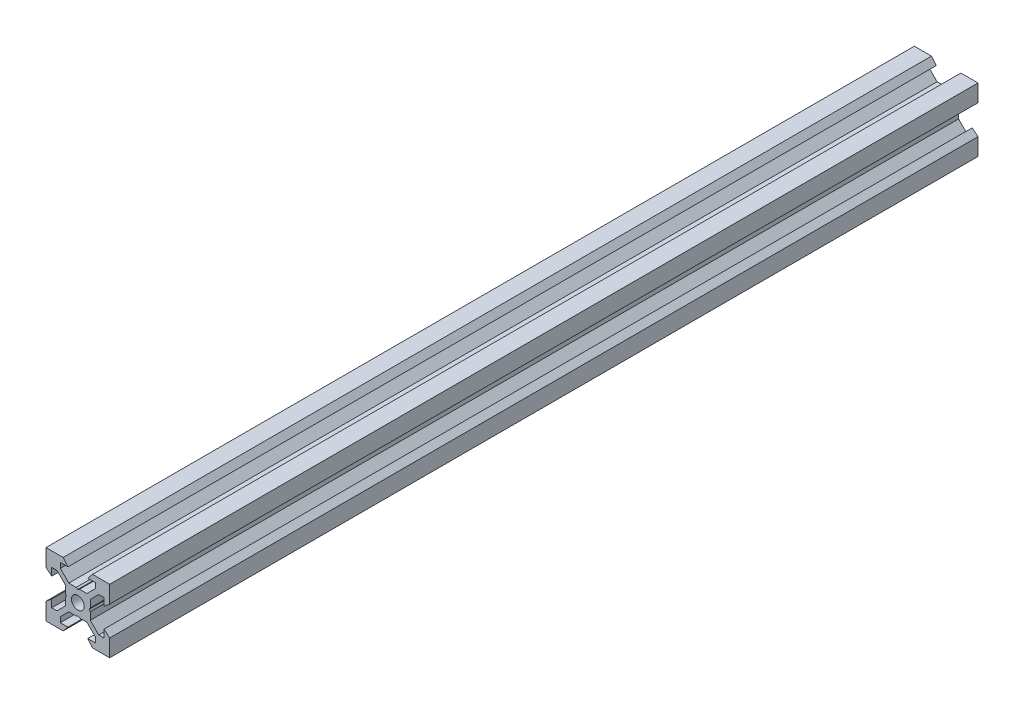
from build123d import *

# Parameters (mm, degrees)
SKETCH1_R           = 2
BOSS_EXTRUDE1_DEPTH = 136.375


with BuildPart() as part:
    # Sketch1 → Boss-Extrude1 (new body, symmetric)
    with BuildSketch(Plane.XY):
        Polygon((10, 10), (10, 4.610379336), (8.2, 3.1), (8.2, 5.5), (6.560660172, 5.5), (3.9, 2.839339828), (3.9, 0.519615242), (3.6, 0), (3.9, -0.519615242), (3.9, -2.839339828), (6.560660172, -5.5), (8.2, -5.5), (8.2, -3.1), (10, -4.610379336), (10, -10), (4.610379336, -10), (3.1, -8.2), (5.5, -8.2), (5.5, -6.560660172), (2.839339828, -3.9), (0.519615242, -3.9), (0, -3.6), (-0.519615242, -3.9), (-2.839339828, -3.9), (-5.5, -6.560660172), (-5.5, -8.2), (-3.1, -8.2), (-4.610379336, -10), (-10, -10), (-10, -4.610379336), (-8.2, -3.1), (-8.2, -5.5), (-6.560660172, -5.5), (-3.9, -2.839339828), (-3.9, -0.519615242), (-3.6, 0), (-3.9, 0.519615242), (-3.9, 2.839339828), (-6.560660172, 5.5), (-8.2, 5.5), (-8.2, 3.1), (-10, 4.610379336), (-10, 10), (-4.610379336, 10), (-3.1, 8.2), (-5.5, 8.2), (-5.5, 6.560660172), (-2.839339828, 3.9), (-0.519615242, 3.9), (0, 3.6), (0.519615242, 3.9), (2.839339828, 3.9), (5.5, 6.560660172), (5.5, 8.2), (3.1, 8.2), (4.610379336, 10), align=None)
        Circle(SKETCH1_R, mode=Mode.SUBTRACT)
    extrude(amount=BOSS_EXTRUDE1_DEPTH, both=True)


solid = part.part
